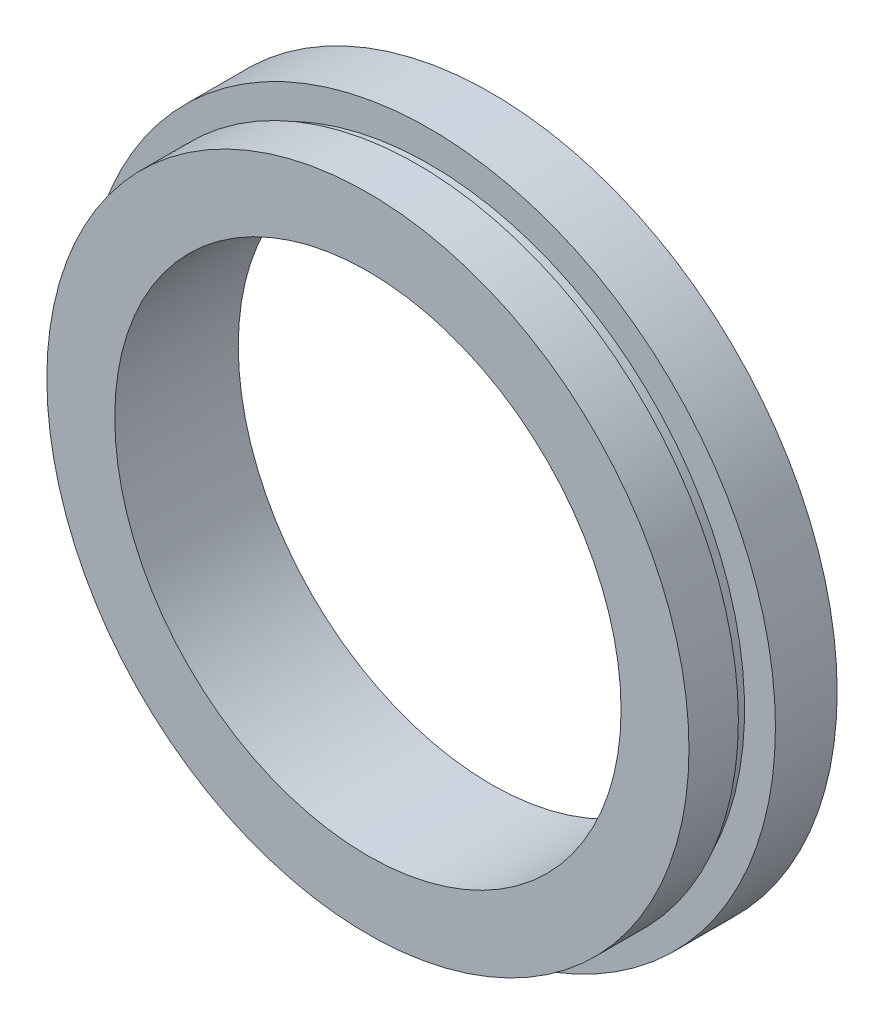
from build123d import *


with BuildPart() as part:
    # 草图1 → 旋转1 (revolve)
    with BuildSketch(Plane(origin=(0, 0, 0), x_dir=(1, 0, 0), z_dir=(0, 1, 0)), mode=Mode.PRIVATE) as revolve_1_sk:
        Polygon((20.5, 0), (20.5, 10), (28, 10), (28, 5), (25.5, 5), (25.5, 4), (26, 4), (26, 0), align=None)
    revolve(revolve_1_sk.sketch.rotate(Axis((0, 0, -19.14057971), (0, 0, 1)), 180), axis=Axis((0, 0, -19.14057971), (0, 0, 1)))  # turned: the seam where the file's is


solid = part.part
